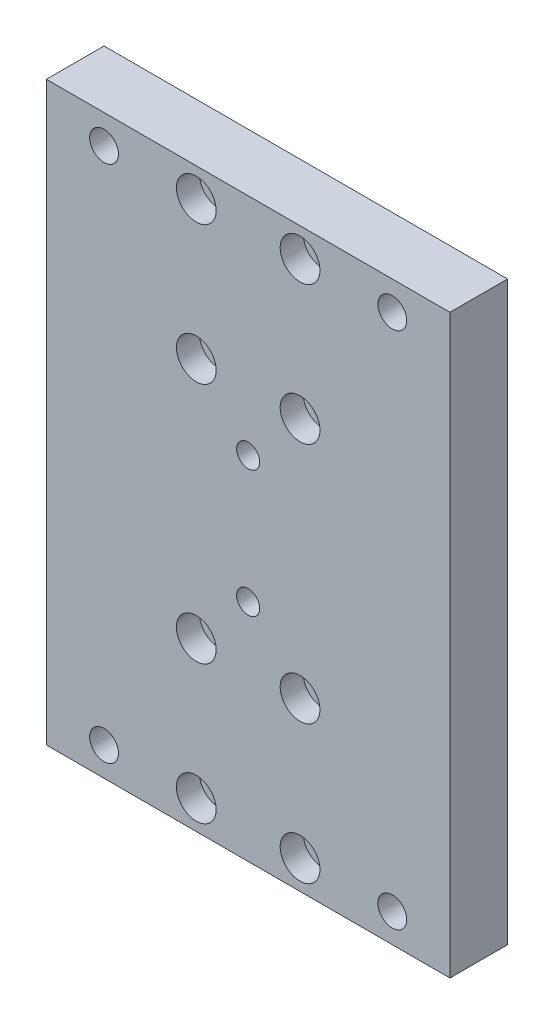
from build123d import *

# Parameters (mm, degrees)
SKETCH1_W           = 70
SKETCH1_H           = 100
BOSS_EXTRUDE1_DEPTH = 10
SKETCH2_R           = 2.5
CUT_EXTRUDE1_DEPTH  = 11
SKETCH3_R           = 1.5
CUT_EXTRUDE2_DEPTH  = 11
SKETCH4_R           = 3.45
CUT_EXTRUDE3_DEPTH  = 4
SKETCH5_R           = 2
CUT_EXTRUDE4_DEPTH  = 11


with BuildPart() as part:
    # Sketch1 → Boss-Extrude1 (new body)
    with BuildSketch(Plane.XY):
        Rectangle(SKETCH1_W, SKETCH1_H)
    extrude(amount=BOSS_EXTRUDE1_DEPTH)

    # Sketch2 → Cut-Extrude1 (cut, through all)
    with BuildSketch(Plane(origin=(0, 0, 0), x_dir=(-1, 0, 0), z_dir=(0, 0, -1))):
        with Locations((-25, 45)):
            Circle(SKETCH2_R)
        with Locations((25, 45)):
            Circle(SKETCH2_R)
        with Locations((-25, -45)):
            Circle(SKETCH2_R)
        with Locations((25, -45)):
            Circle(SKETCH2_R)
    extrude(amount=-CUT_EXTRUDE1_DEPTH, mode=Mode.SUBTRACT)

    # Sketch3 → Cut-Extrude2 (cut, through all)
    with BuildSketch(Plane(origin=(0, 0, 0), x_dir=(-1, 0, 0), z_dir=(0, 0, -1))):
        with Locations((9, 21)):
            Circle(SKETCH3_R)
        with Locations((9, 45)):
            Circle(SKETCH3_R)
        with Locations((-9, 21)):
            Circle(SKETCH3_R)
        with Locations((-9, 45)):
            Circle(SKETCH3_R)
        with Locations((9, -45)):
            Circle(SKETCH3_R)
        with Locations((9, -21)):
            Circle(SKETCH3_R)
        with Locations((-9, -45)):
            Circle(SKETCH3_R)
        with Locations((-9, -21)):
            Circle(SKETCH3_R)
    extrude(amount=-CUT_EXTRUDE2_DEPTH, mode=Mode.SUBTRACT)

    # Sketch4 → Cut-Extrude3 (cut)
    with BuildSketch(Plane.XY.offset(10)):
        with Locations((-9, 45)):
            Circle(SKETCH4_R)
        with Locations((-9, 21)):
            Circle(SKETCH4_R)
        with Locations((9, 21)):
            Circle(SKETCH4_R)
        with Locations((9, 45)):
            Circle(SKETCH4_R)
        with Locations((9, -21)):
            Circle(SKETCH4_R)
        with Locations((-9, -21)):
            Circle(SKETCH4_R)
        with Locations((-9, -45)):
            Circle(SKETCH4_R)
        with Locations((9, -45)):
            Circle(SKETCH4_R)
    extrude(amount=-CUT_EXTRUDE3_DEPTH, mode=Mode.SUBTRACT)

    # Sketch5 → Cut-Extrude4 (cut, through all)
    with BuildSketch(Plane.XY.offset(10)):
        with Locations((0, -11)):
            Circle(SKETCH5_R)
        with Locations((0, 11)):
            Circle(SKETCH5_R)
    extrude(amount=-CUT_EXTRUDE4_DEPTH, mode=Mode.SUBTRACT)


solid = part.part
